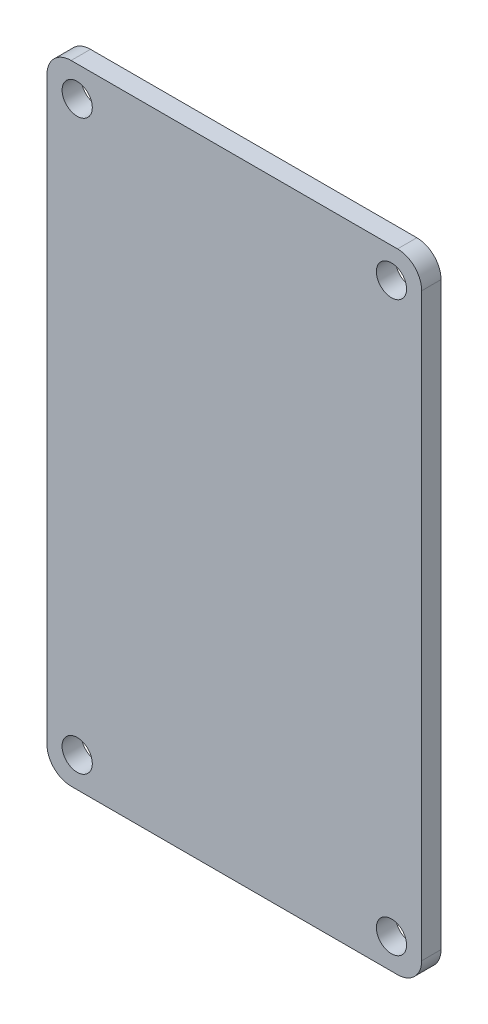
from build123d import *

# Parameters (mm, degrees)
SKETCH1_R           = 1.25
BOSS_EXTRUDE1_DEPTH = 1.6


with BuildPart() as part:
    # Sketch1 → Boss-Extrude1 (new body)
    with BuildSketch(Plane.XY):
        with BuildLine():
            Line((-13.5, 26), (13.5, 26))
            ThreePointArc((13.5, 26), (14.914213562, 25.414213562), (15.5, 24))
            Line((15.5, 24), (15.5, -24))
            ThreePointArc((15.5, -24), (14.914213562, -25.414213562), (13.5, -26))
            Line((13.5, -26), (-13.5, -26))
            ThreePointArc((-13.5, -26), (-14.914213562, -25.414213562), (-15.5, -24))
            Line((-15.5, -24), (-15.5, 24))
            ThreePointArc((-15.5, 24), (-14.914213562, 25.414213562), (-13.5, 26))
        make_face()
        with Locations((-13, 23.5)):
            Circle(SKETCH1_R, mode=Mode.SUBTRACT)
        with Locations((13, 23.5)):
            Circle(SKETCH1_R, mode=Mode.SUBTRACT)
        with Locations((13, -23.5)):
            Circle(SKETCH1_R, mode=Mode.SUBTRACT)
        with Locations((-13, -23.5)):
            Circle(SKETCH1_R, mode=Mode.SUBTRACT)
    extrude(amount=BOSS_EXTRUDE1_DEPTH)


solid = part.part
